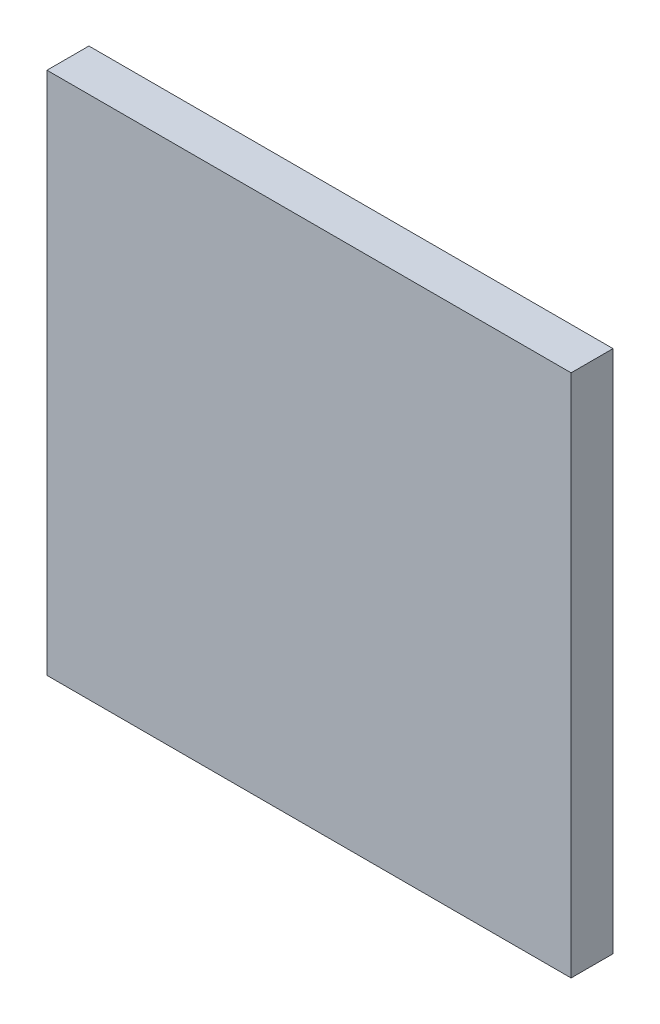
from build123d import *

# Parameters (mm, degrees)
EXTRUDE_1_DEPTH = 4


with BuildPart() as part:
    # 草图1 → 凸台-拉伸1 (new body)
    with BuildSketch(Plane.XY):
        Polygon((416.617543458, 154.384302534), (416.617543458, 179.384302534), (466.617543458, 179.384302534), (466.617543458, 129.384302534), (416.617543458, 129.384302534), align=None)
    extrude(amount=EXTRUDE_1_DEPTH)


solid = part.part
